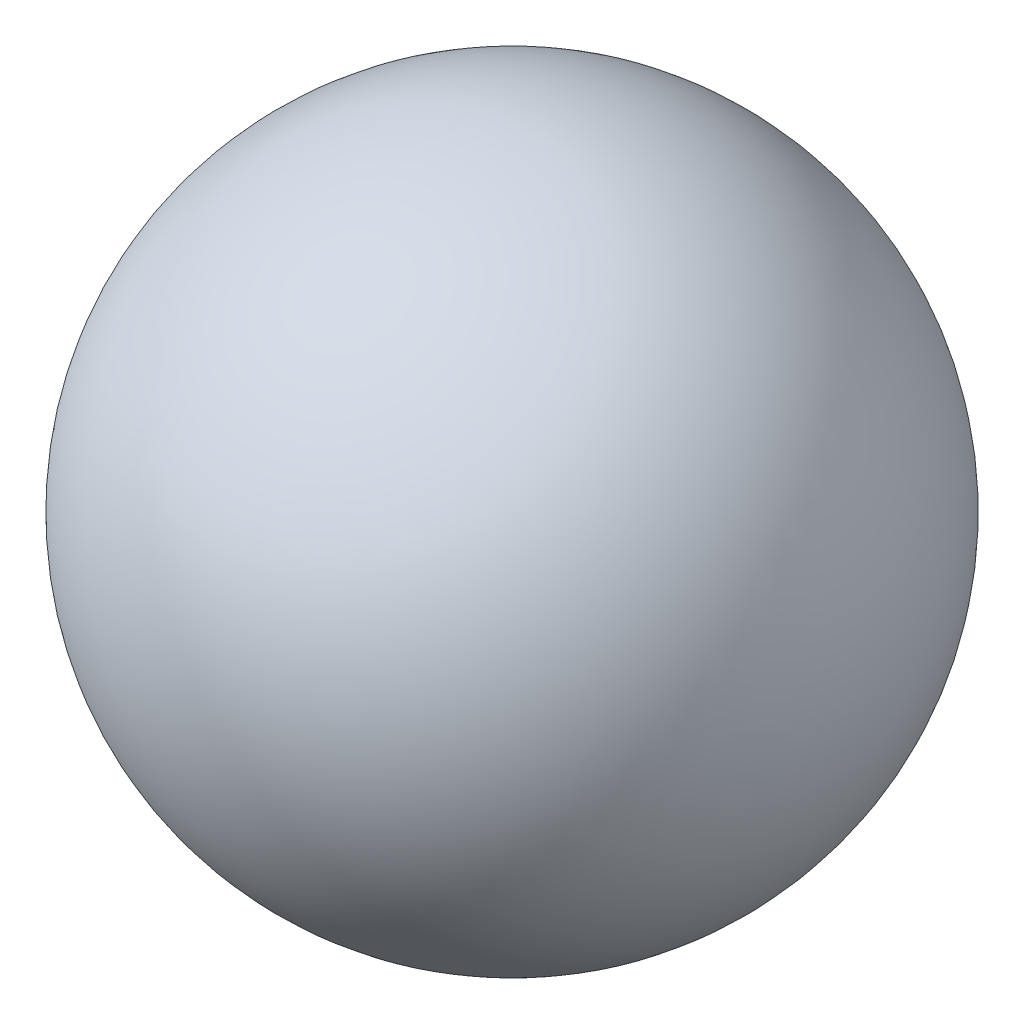
from build123d import *


with BuildPart() as part:
    # Esquisse1 → Révolution1 (revolve)
    with BuildSketch(Plane.XY):
        with BuildLine():
            Line((0, 2), (0, -2))
            ThreePointArc((0, -2), (2, 0), (0, 2))
        make_face()
    revolve(axis=Axis((0, 17.003113553, 0), (0, -1, 0)))


solid = part.part
